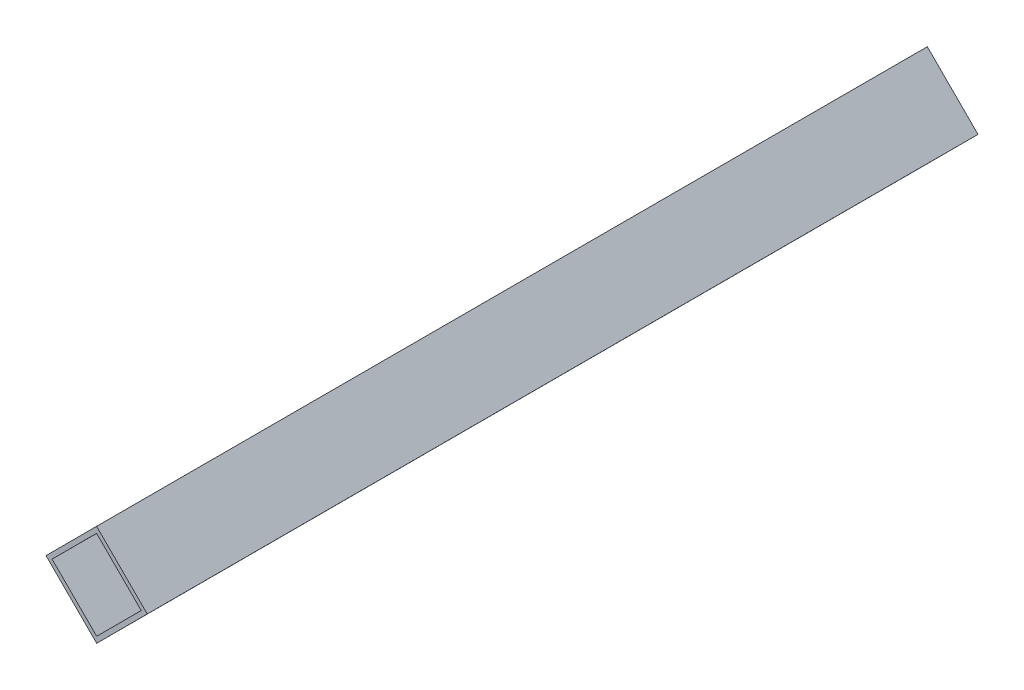
from build123d import *

# Parameters (mm, degrees)
EXTRUDE_1_DEPTH = 290


with BuildPart() as part:
    # 草圖1 → 填料-伸長1 (new body)
    with BuildSketch(Plane.XY):
        Polygon((0, 0), (17.69379362, -17.661530719), (0.032262901, -35.355324339), (-17.661530719, -17.69379362), align=None)
        Polygon((0.001935774, -2.12131946), (-15.540211259, -17.691857846), (0.030327127, -33.234004879), (15.57247416, -17.663466493), align=None, mode=Mode.SUBTRACT)
    extrude(amount=EXTRUDE_1_DEPTH)


solid = part.part
